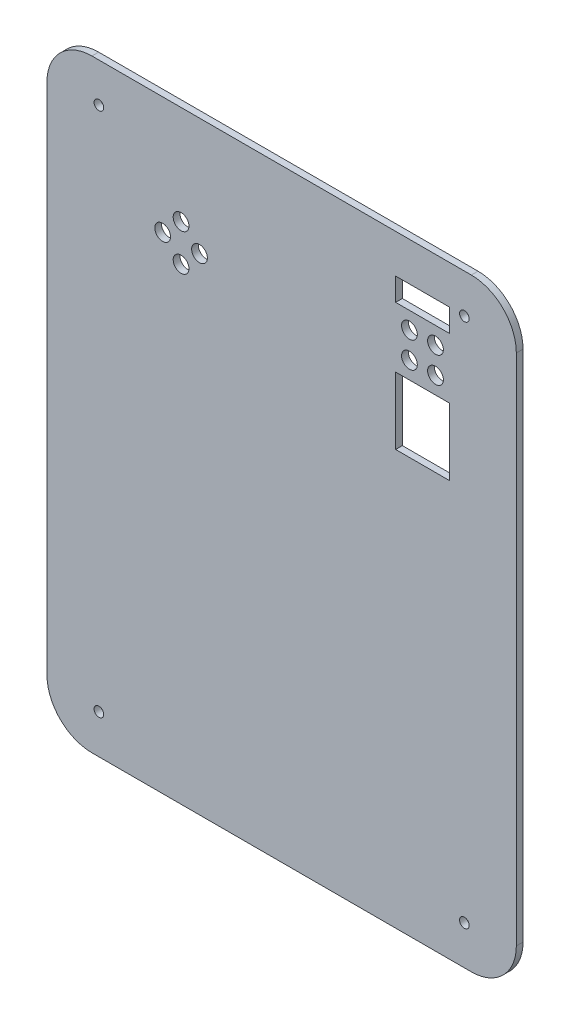
from build123d import *

# Parameters (mm, degrees)
BOSS_EXTRUDE1_DEPTH         = 2.54
SKETCH6_R                   = 2.9845
SKETCH6_W                   = 20.32
SKETCH6_H                   = 25.4
SKETCH6_H_2                 = 8.636
CUT_EXTRUDE1_DEPTH          = 3.54
F_27_0_144_DIAMETER_HOLE1_D = 3.6576


with BuildPart() as part:
    # Sketch1 → Boss-Extrude1 (new body)
    with BuildSketch(Plane(origin=(0, 0, 0), x_dir=(0, 1, 0), z_dir=(0, 0, 1))):
        with BuildLine():
            Line((-97.2566, -88.9), (97.2566, -88.9))
            ThreePointArc((97.2566, -88.9), (109.308103714, -83.908103714), (114.3, -71.8566))
            Line((114.3, -71.8566), (114.3, 71.8566))
            ThreePointArc((114.3, 71.8566), (109.308103714, 83.908103714), (97.2566, 88.9))
            Line((97.2566, 88.9), (-97.2566, 88.9))
            ThreePointArc((-97.2566, 88.9), (-109.308103714, 83.908103714), (-114.3, 71.8566))
            Line((-114.3, 71.8566), (-114.3, -71.8566))
            ThreePointArc((-114.3, -71.8566), (-109.308103714, -83.908103714), (-97.2566, -88.9))
        make_face()
    extrude(amount=BOSS_EXTRUDE1_DEPTH)

    # Sketch6 → Cut-Extrude1 (cut, through all)
    with BuildSketch(Plane.XY.offset(2.54)):
        with Locations((58.279140867, 84.504640867)):
            Circle(SKETCH6_R)
        with Locations((58.279140867, 74.626359133)):
            Circle(SKETCH6_R)
        with Locations((48.400859133, 74.626359133)):
            Circle(SKETCH6_R)
        with Locations((48.400859133, 84.504640867)):
            Circle(SKETCH6_R)
        with Locations((-38.1, 76.835)):
            Circle(SKETCH6_R)
        with Locations((-31.115, 69.85)):
            Circle(SKETCH6_R)
        with Locations((-38.1, 62.865)):
            Circle(SKETCH6_R)
        with Locations((-45.085, 69.85)):
            Circle(SKETCH6_R)
        with Locations((53.34, 55.4355)):
            Rectangle(SKETCH6_W, SKETCH6_H)
        with Locations((53.34, 95.3135)):
            Rectangle(SKETCH6_W, SKETCH6_H_2)
    extrude(amount=-CUT_EXTRUDE1_DEPTH, mode=Mode.SUBTRACT)

    # #27 (0.144) Diameter Hole1 (through all)
    with Locations(Plane.XY.offset(2.54)):
        with Locations((69.21913, 99.508615), (69.21913, -99.508615), (-69.21913, 99.508615), (-69.21913, -99.508615)):
            Hole(F_27_0_144_DIAMETER_HOLE1_D / 2)


solid = part.part
